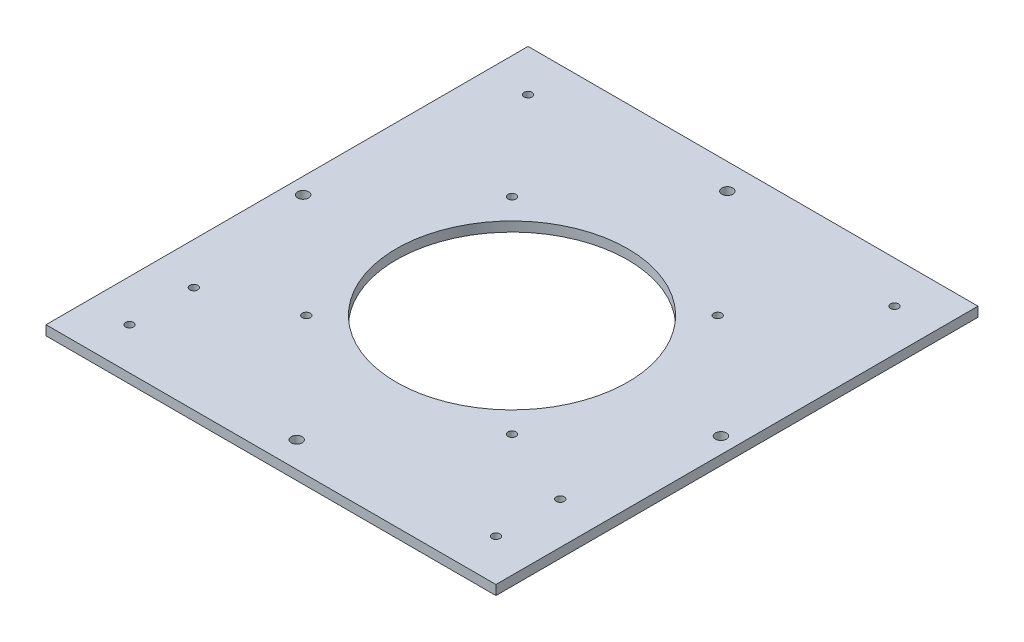
from build123d import *

# Parameters (mm, degrees)
SKETCH_1_W           = 140
SKETCH_1_H           = 3
EXTRUDE_1_DEPTH      = 150
CUT_EXTRUDE_1_REACH  = 5
SKETCH_2_R           = 36
HOLE_WIZARD_M3_1_D   = 2.5
HOLE_WIZARD_M3_1_2_D = 3.4
HOLE_WIZARD_M3_2_D   = 2.5


with BuildPart() as part:
    # 草图1 → 拉伸-薄壁1 (new body)
    with BuildSketch(Plane.XY):
        with Locations((82, 225.557982809)):
            Rectangle(SKETCH_1_W, SKETCH_1_H)
    extrude(amount=EXTRUDE_1_DEPTH)

    # 草图2 → 切除-拉伸1 (cut, up to next)
    with BuildSketch(Plane.XZ.offset(-224.057982809), mode=Mode.PRIVATE) as cut_extrude_1_sk1:
        with Locations((82, 75)):
            Circle(SKETCH_2_R)
    cut_extrude_1_tool1 = extrude(cut_extrude_1_sk1.sketch, amount=-CUT_EXTRUDE_1_REACH, mode=Mode.PRIVATE) & part.part
    add(cut_extrude_1_tool1.solids().sort_by_distance((82, 224.057983, 75))[0], mode=Mode.SUBTRACT)

    # Hole Wizard M3 _1 (through all)
    with Locations(Plane(origin=(0, 224.057982809, 0), x_dir=(-1, 0, 0), z_dir=(0, -1, 0))):
        with Locations((-50, -107), (-50, -43), (-114, -43), (-114, -107)):
            Hole(HOLE_WIZARD_M3_1_D / 2)

    # Hole Wizard M3 _1 2 (through all)
    with Locations(Plane(origin=(0, 224.057982809, 0), x_dir=(-1, 0, 0), z_dir=(0, -1, 0))):
        with Locations((-82, -142), (-147, -75), (-82, -8), (-17, -75)):
            Hole(HOLE_WIZARD_M3_1_2_D / 2)

    # M3 螺纹孔的螺纹孔钻头2 (through all)
    with Locations(Plane(origin=(0, 224.057982809, 0), x_dir=(-1, 0, 0), z_dir=(0, -1, 0))):
        with Locations((-139, -137), (-139, -117), (-139, -13), (-25, -137), (-25, -117), (-25, -13)):
            Hole(HOLE_WIZARD_M3_2_D / 2)


solid = part.part
